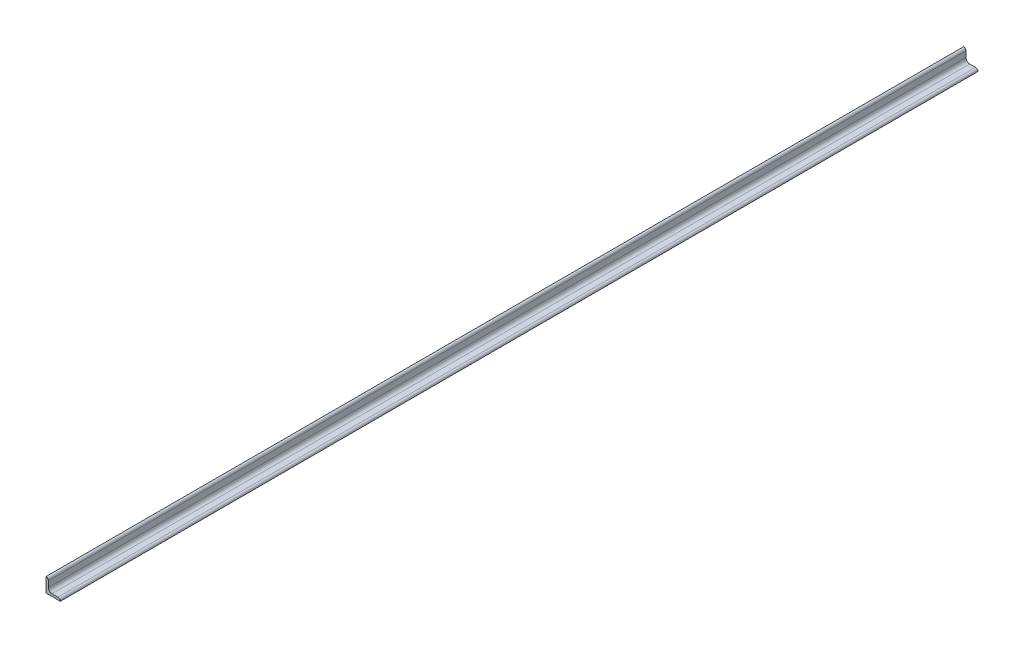
from build123d import *

# Parameters (mm, degrees)
BOSS_EXTRUDE1_DEPTH = 609.6


with BuildPart() as part:
    # Sketch1 → Boss-Extrude1 (new body, symmetric)
    with BuildSketch(Plane.XY):
        with BuildLine():
            Line((0, 0), (0, 19.05))
            Line((0, 19.05), (0.00508, 19.05))
            ThreePointArc((0.00508, 19.05), (2.246551928, 18.121551928), (3.175, 15.88008))
            Line((3.175, 15.88008), (3.175, 7.9375))
            ThreePointArc((3.175, 7.9375), (4.569903955, 4.569903955), (7.9375, 3.175))
            Line((7.9375, 3.175), (15.88008, 3.175))
            ThreePointArc((15.88008, 3.175), (18.121551928, 2.246551928), (19.05, 0.00508))
            Line((19.05, 0.00508), (19.05, 0))
            Line((19.05, 0), (0, 0))
        make_face()
    extrude(amount=BOSS_EXTRUDE1_DEPTH, both=True)


solid = part.part
